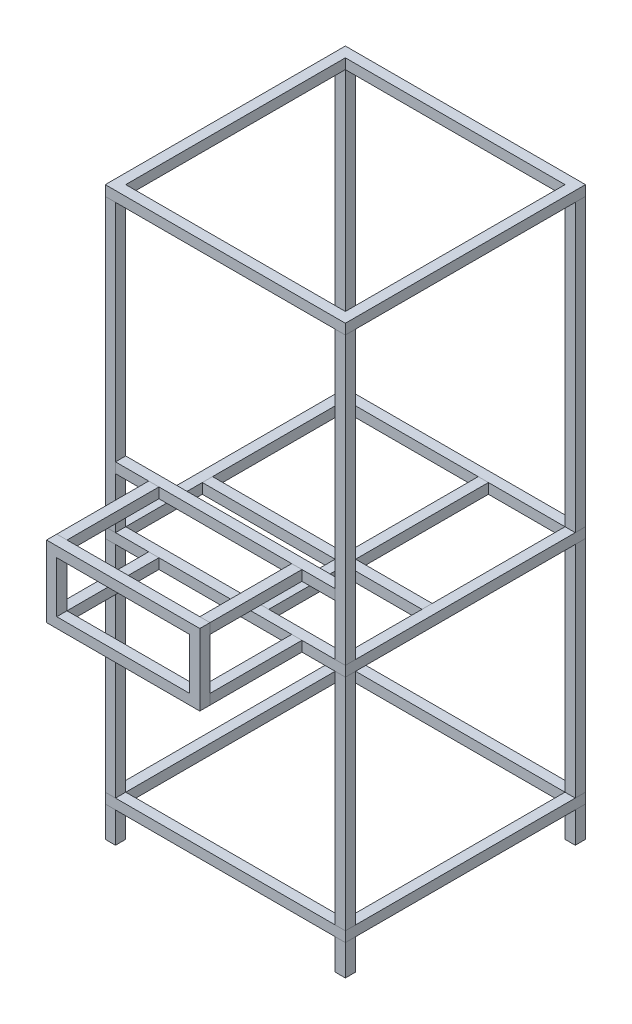
from build123d import *

# Parameters (mm, degrees)
SKETCH_1_W        = 470
SKETCH_1_H        = 470
SKETCH_1_W_2      = 430
SKETCH_1_H_2      = 430
EXTRUDE_1_DEPTH   = 20
SKETCH_2_W        = 20
SKETCH_2_H        = 20
EXTRUDE_2_DEPTH   = 560
EXTRUDE_2_2_DEPTH = 560
EXTRUDE_2_3_DEPTH = 560
EXTRUDE_2_4_DEPTH = 560
SKETCH_3_W        = 470
SKETCH_3_H        = 470
SKETCH_3_W_2      = 430
SKETCH_3_H_2      = 430
EXTRUDE_3_DEPTH   = 20
SKETCH_4_W        = 470
SKETCH_4_H        = 470
SKETCH_4_W_2      = 430
SKETCH_4_H_2      = 430
EXTRUDE_4_DEPTH   = 20
SKETCH_5_W        = 20
SKETCH_5_H        = 20
EXTRUDE_5_DEPTH   = 430
EXTRUDE_5_2_DEPTH = 430
EXTRUDE_5_3_DEPTH = 430
EXTRUDE_5_4_DEPTH = 430
SKETCH_6_W        = 20
SKETCH_6_H        = 20
EXTRUDE_6_DEPTH   = 60
EXTRUDE_6_2_DEPTH = 60
EXTRUDE_6_3_DEPTH = 60
EXTRUDE_6_4_DEPTH = 60
SKETCH_8_W        = 430
SKETCH_8_H        = 20
EXTRUDE_7_DEPTH   = 20
EXTRUDE_START     = 180
SKETCH_9_W        = 300
SKETCH_9_H        = 140
SKETCH_9_W_2      = 260
SKETCH_9_H_2      = 100
EXTRUDE_8_DEPTH   = 20
SKETCH_10_W       = 20
SKETCH_10_H       = 20
EXTRUDE_9_DEPTH   = 180
EXTRUDE_9_2_DEPTH = 180
EXTRUDE_9_3_DEPTH = 180
EXTRUDE_9_4_DEPTH = 180
SKETCH_11_W       = 20
SKETCH_11_H       = 430
SKETCH_11_W_2     = 430
SKETCH_11_H_2     = 20
EXTRUDE_10_DEPTH  = 20


with BuildPart() as part:
    # 스케치1 → 보스-돌출1 (new body)
    with BuildSketch(Plane(origin=(0, 0, 0), x_dir=(1, 0, 0), z_dir=(0, 1, 0))):
        with Locations((235, 235)):
            Rectangle(SKETCH_1_W, SKETCH_1_H)
        with Locations((235, 235)):
            Rectangle(SKETCH_1_W_2, SKETCH_1_H_2, mode=Mode.SUBTRACT)
    extrude(amount=-EXTRUDE_1_DEPTH)


with BuildPart() as body_2:
    # 스케치2 → 보스-돌출2 (new body)
    with BuildSketch(Plane.XZ.offset(20)):
        with Locations((10, -10)):
            Rectangle(SKETCH_2_W, SKETCH_2_H)
    extrude(amount=EXTRUDE_2_DEPTH)


with BuildPart() as body_3:
    # 스케치2 → Extrude 2 2 (new body)
    with BuildSketch(Plane.XZ.offset(20)):
        with Locations((460, -10)):
            Rectangle(SKETCH_2_W, SKETCH_2_H)
    extrude(amount=EXTRUDE_2_2_DEPTH)


with BuildPart() as body_4:
    # 스케치2 → Extrude 2 3 (new body)
    with BuildSketch(Plane.XZ.offset(20)):
        with Locations((460, -460)):
            Rectangle(SKETCH_2_W, SKETCH_2_H)
    extrude(amount=EXTRUDE_2_3_DEPTH)


with BuildPart() as body_5:
    # 스케치2 → Extrude 2 4 (new body)
    with BuildSketch(Plane.XZ.offset(20)):
        with Locations((10, -460)):
            Rectangle(SKETCH_2_W, SKETCH_2_H)
    extrude(amount=EXTRUDE_2_4_DEPTH)


with BuildPart() as body_6:
    # 스케치3 → 보스-돌출3 (new body)
    with BuildSketch(Plane(origin=(0, -1030, 0), x_dir=(1, 0, 0), z_dir=(0, 1, 0))):
        with Locations((235, 235)):
            Rectangle(SKETCH_3_W, SKETCH_3_H)
        with Locations((235, 235)):
            Rectangle(SKETCH_3_W_2, SKETCH_3_H_2, mode=Mode.SUBTRACT)
    extrude(amount=-EXTRUDE_3_DEPTH)


with BuildPart() as body_7:
    # 스케치4 → 보스-돌출4 (new body)
    with BuildSketch(Plane(origin=(0, -600, 0), x_dir=(1, 0, 0), z_dir=(0, 1, 0))):
        with Locations((235, 235)):
            Rectangle(SKETCH_4_W, SKETCH_4_H)
        with Locations((235, 235)):
            Rectangle(SKETCH_4_W_2, SKETCH_4_H_2, mode=Mode.SUBTRACT)
    extrude(amount=EXTRUDE_4_DEPTH)


with BuildPart() as body_8:
    # 스케치5 → 보스-돌출5 (new body)
    with BuildSketch(Plane.XZ.offset(600)):
        with Locations((10, -10)):
            Rectangle(SKETCH_5_W, SKETCH_5_H)
    extrude(amount=EXTRUDE_5_DEPTH)


with BuildPart() as body_9:
    # 스케치5 → Extrude 5 2 (new body)
    with BuildSketch(Plane.XZ.offset(600)):
        with Locations((460, -10)):
            Rectangle(SKETCH_5_W, SKETCH_5_H)
    extrude(amount=EXTRUDE_5_2_DEPTH)


with BuildPart() as body_10:
    # 스케치5 → Extrude 5 3 (new body)
    with BuildSketch(Plane.XZ.offset(600)):
        with Locations((460, -460)):
            Rectangle(SKETCH_5_W, SKETCH_5_H)
    extrude(amount=EXTRUDE_5_3_DEPTH)


with BuildPart() as body_11:
    # 스케치5 → Extrude 5 4 (new body)
    with BuildSketch(Plane.XZ.offset(600)):
        with Locations((10, -460)):
            Rectangle(SKETCH_5_W, SKETCH_5_H)
    extrude(amount=EXTRUDE_5_4_DEPTH)


with BuildPart() as body_12:
    # 스케치6 → 보스-돌출6 (new body)
    with BuildSketch(Plane.XZ.offset(1050)):
        with Locations((10, -10)):
            Rectangle(SKETCH_6_W, SKETCH_6_H)
    extrude(amount=EXTRUDE_6_DEPTH)


with BuildPart() as body_13:
    # 스케치6 → Extrude 6 2 (new body)
    with BuildSketch(Plane.XZ.offset(1050)):
        with Locations((460, -10)):
            Rectangle(SKETCH_6_W, SKETCH_6_H)
    extrude(amount=EXTRUDE_6_2_DEPTH)


with BuildPart() as body_14:
    # 스케치6 → Extrude 6 3 (new body)
    with BuildSketch(Plane.XZ.offset(1050)):
        with Locations((460, -460)):
            Rectangle(SKETCH_6_W, SKETCH_6_H)
    extrude(amount=EXTRUDE_6_3_DEPTH)


with BuildPart() as body_15:
    # 스케치6 → Extrude 6 4 (new body)
    with BuildSketch(Plane.XZ.offset(1050)):
        with Locations((10, -460)):
            Rectangle(SKETCH_6_W, SKETCH_6_H)
    extrude(amount=EXTRUDE_6_4_DEPTH)


with BuildPart() as body_16:
    # 스케치8 → 보스-돌출7 (new body)
    with BuildSketch(Plane(origin=(0, -460, 0), x_dir=(1, 0, 0), z_dir=(0, 1, 0))):
        with Locations((235, 10)):
            Rectangle(SKETCH_8_W, SKETCH_8_H)
    extrude(amount=-EXTRUDE_7_DEPTH)


with BuildPart() as body_17:
    # 스케치9 → 보스-돌출8 (new body)
    with BuildSketch(Plane.XY.offset(EXTRUDE_START)):
        with Locations((235, -530)):
            Rectangle(SKETCH_9_W, SKETCH_9_H)
        with Locations((235, -530)):
            Rectangle(SKETCH_9_W_2, SKETCH_9_H_2, mode=Mode.SUBTRACT)
    extrude(amount=EXTRUDE_8_DEPTH)


with BuildPart() as body_18:
    # 스케치10 → 보스-돌출9 (new body)
    with BuildSketch(Plane.XY):
        with Locations((95, -470)):
            Rectangle(SKETCH_10_W, SKETCH_10_H)
    extrude(amount=EXTRUDE_9_DEPTH)


with BuildPart() as body_19:
    # 스케치10 → Extrude 9 2 (new body)
    with BuildSketch(Plane.XY):
        with Locations((375, -470)):
            Rectangle(SKETCH_10_W, SKETCH_10_H)
    extrude(amount=EXTRUDE_9_2_DEPTH)


with BuildPart() as body_20:
    # 스케치10 → Extrude 9 3 (new body)
    with BuildSketch(Plane.XY):
        with Locations((375, -590)):
            Rectangle(SKETCH_10_W, SKETCH_10_H)
    extrude(amount=EXTRUDE_9_3_DEPTH)


with BuildPart() as body_21:
    # 스케치10 → Extrude 9 4 (new body)
    with BuildSketch(Plane.XY):
        with Locations((95, -590)):
            Rectangle(SKETCH_10_W, SKETCH_10_H)
    extrude(amount=EXTRUDE_9_4_DEPTH)


with BuildPart() as body_22:
    # 스케치11 → 보스-돌출10 (new body)
    with BuildSketch(Plane.XZ.offset(600)):
        with Locations((290, -235)):
            Rectangle(SKETCH_11_W, SKETCH_11_H)
        with Locations((235, -180)):
            Rectangle(SKETCH_11_W_2, SKETCH_11_H_2)
    extrude(amount=-EXTRUDE_10_DEPTH)


solid = Compound([part.part, body_2.part, body_3.part, body_4.part, body_5.part, body_6.part, body_7.part, body_8.part, body_9.part, body_10.part, body_11.part, body_12.part, body_13.part, body_14.part, body_15.part, body_16.part, body_17.part, body_18.part, body_19.part, body_20.part, body_21.part, body_22.part])
